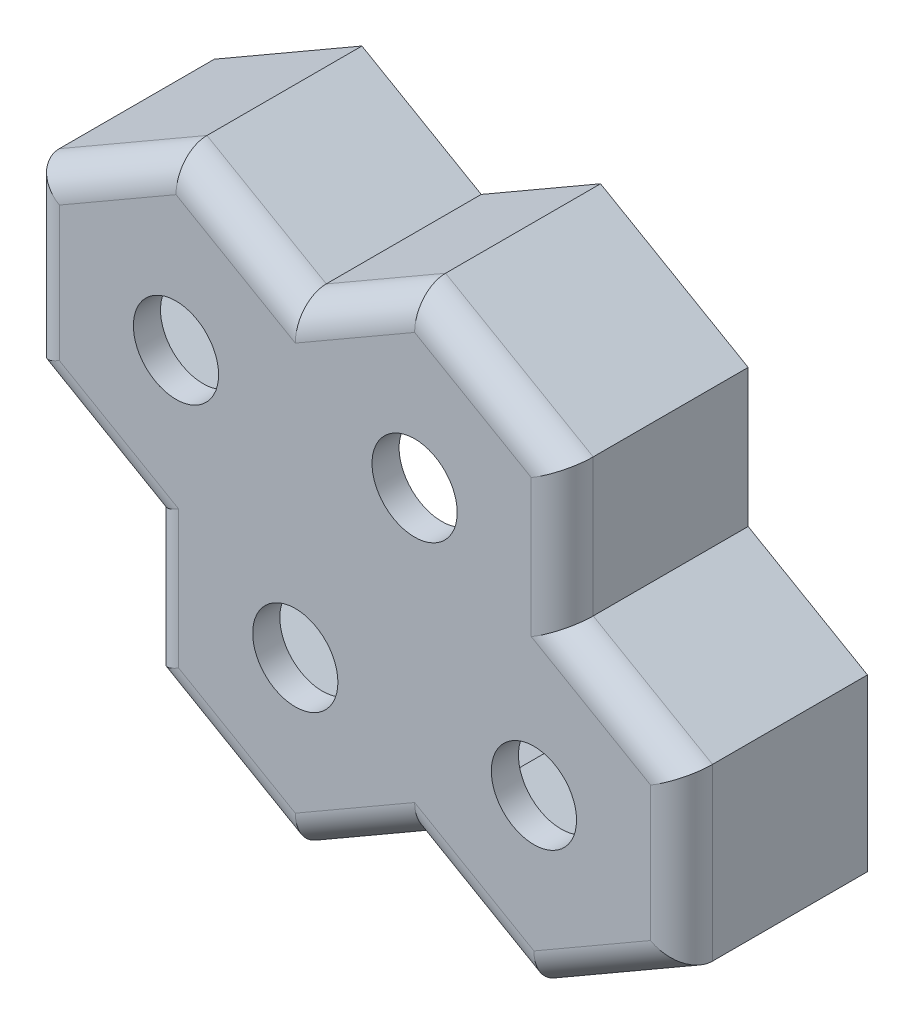
from build123d import *

# Parameters (mm, degrees)
BOSS_EXTRUDE1_DEPTH = 2
BOSS_EXTRUDE2_DEPTH = 10
SKETCH1_4_R         = 2.75
CUT_EXTRUDE1_DEPTH  = 2
FILLET1_R           = 2
SKETCH1_5_R         = 5.656929669
CUT_EXTRUDE5_DEPTH  = 0.25


with BuildPart() as part:
    # Sketch1 → Boss-Extrude1 (new body)
    with BuildSketch(Plane.XY):
        Polygon((-24.926279442, 5.5), (-24.926279442, -5.5), (-17.226279442, -9.945597073), (-17.226279442, -18.836791218), (-7.7, -24.336791218), (0, -19.891194146), (7.7, -24.336791218), (17.226279442, -18.836791218), (17.226279442, -7.836791218), (9.526279442, -3.391194146), (9.526279442, 5.5), (0, 11), (-7.7, 6.554402927), (-15.4, 11), align=None)
    extrude(amount=BOSS_EXTRUDE1_DEPTH)

    # Sketch1_3 → Boss-Extrude2 (add)
    with BuildSketch(Plane.XY):
        Polygon((-15.4, 11), (-24.926279442, 5.5), (-24.926279442, -5.5), (-17.226279442, -9.945597073), (-17.226279442, -18.836791218), (-7.7, -24.336791218), (0, -19.891194146), (7.7, -24.336791218), (17.226279442, -18.836791218), (17.226279442, -7.836791218), (9.526279442, -3.391194146), (9.526279442, 5.5), (0, 11), (-7.7, 6.554402927), align=None)
        Polygon((-24.176279442, 5.066987298), (-15.4, 10.133974596), (-7.7, 5.688377523), (0, 10.133974596), (8.776279442, 5.066987298), (8.776279442, -3.824206847), (16.476279442, -8.26980392), (16.476279442, -18.403778516), (7.7, -23.470765814), (0, -19.025168742), (-7.7, -23.470765814), (-16.476279442, -18.403778516), (-16.476279442, -9.512584371), (-24.176279442, -5.066987298), align=None, mode=Mode.SUBTRACT)
    extrude(amount=-BOSS_EXTRUDE2_DEPTH)

    # Sketch1_4 → Cut-Extrude1 (cut)
    with BuildSketch(Plane.XY):
        with Locations((-15.4, 0)):
            Circle(SKETCH1_4_R)
        Circle(SKETCH1_4_R)
        with Locations((-7.7, -13.336791218)):
            Circle(SKETCH1_4_R)
        with Locations((7.7, -13.336791218)):
            Circle(SKETCH1_4_R)
    extrude(amount=CUT_EXTRUDE1_DEPTH, mode=Mode.SUBTRACT)

    # Fillet1
    fillet1_edges = [part.edges().sort_by_distance(p)[0] for p in [
        (4.763139721, 8.25, 2),
        (9.526279442, 1.054402927, 2),
        (13.376279442, -5.613992682, 2),
        (17.226279442, -13.336791218, 2),
        (12.463139721, -21.586791218, 2),
        (3.85, -22.113992682, 2),
        (-3.85, -22.113992682, 2),
        (-12.463139721, -21.586791218, 2),
        (-17.226279442, -14.391194146, 2),
        (-21.076279442, -7.722798536, 2),
        (-24.926279442, 0, 2),
        (-20.163139721, 8.25, 2),
        (-11.55, 8.777201464, 2),
        (-3.85, 8.777201464, 2),
    ]]
    fillet(fillet1_edges, radius=FILLET1_R)

    # Sketch1_5 → Cut-Extrude5 (cut)
    with BuildSketch(Plane.XY):
        with Locations((-15.4, 0)):
            Circle(SKETCH1_5_R)
        Circle(SKETCH1_5_R)
        with Locations((7.7, -13.336791218)):
            Circle(SKETCH1_5_R)
        with Locations((-7.7, -13.336791218)):
            Circle(SKETCH1_5_R)
    extrude(amount=CUT_EXTRUDE5_DEPTH, mode=Mode.SUBTRACT)


solid = part.part
